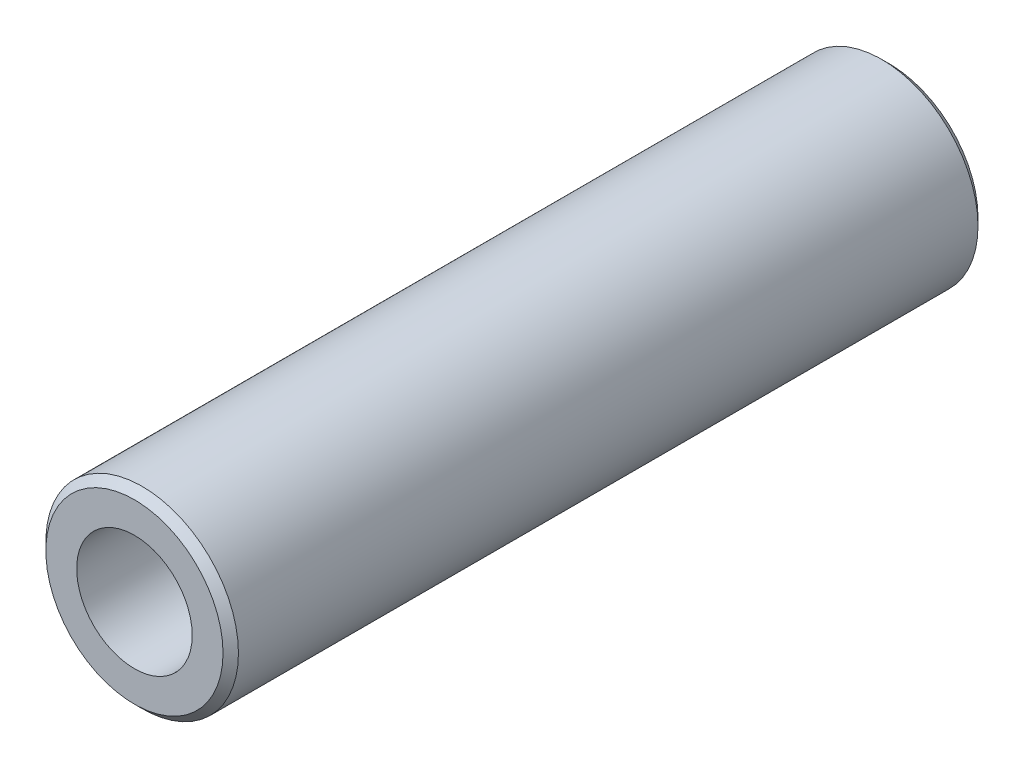
from build123d import *

# Parameters (mm, degrees)
SKETCH2_R           = 6.25
SKETCH2_R_2         = 3.75
EXTRUDE_THIN1_DEPTH = 24.5
CHAMFER1_SIZE       = 0.5


with BuildPart() as part:
    # Sketch2 → Extrude-Thin1 (new body, symmetric)
    with BuildSketch(Plane.XY):
        Circle(SKETCH2_R)
        Circle(SKETCH2_R_2, mode=Mode.SUBTRACT)
    extrude(amount=EXTRUDE_THIN1_DEPTH, both=True)

    # Chamfer1
    chamfer1_edges = [part.edges().sort_by_distance(p)[0] for p in [
        (-6.25, 0, -24.5),
        (-6.25, 0, 24.5),
    ]]
    chamfer(chamfer1_edges, length=CHAMFER1_SIZE)


solid = part.part
